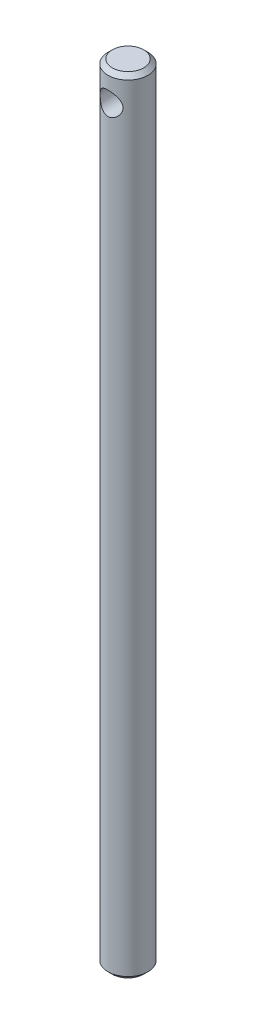
from build123d import *

# Parameters (mm, degrees)
SKETCH1_R               = 14
BOSS_EXTRUDE1_DEPTH     = 550
SKETCH2_R               = 8
CUT_EXTRUDE1_DEPTH      = 15
CUT_EXTRUDE1_DEPTH_BACK = 15
CHAMFER1_SIZE           = 3


with BuildPart() as part:
    # Sketch1 → Boss-Extrude1 (new body)
    with BuildSketch(Plane(origin=(0, 0, 0), x_dir=(1, 0, 0), z_dir=(0, 1, 0))):
        Circle(SKETCH1_R)
    extrude(amount=BOSS_EXTRUDE1_DEPTH)

    # Sketch2 → Cut-Extrude1 (cut, two sides)
    with BuildSketch(Plane.XY) as cut_extrude1_sk:
        with Locations((0, 530)):
            Circle(SKETCH2_R)
    extrude(amount=CUT_EXTRUDE1_DEPTH, mode=Mode.SUBTRACT)
    extrude(cut_extrude1_sk.sketch, amount=-CUT_EXTRUDE1_DEPTH_BACK, mode=Mode.SUBTRACT)

    # Chamfer1
    chamfer1_edges = [part.edges().sort_by_distance(p)[0] for p in [
        (-14, 0, 0),
        (-14, 550, 0),
    ]]
    chamfer(chamfer1_edges, length=CHAMFER1_SIZE)


solid = part.part
